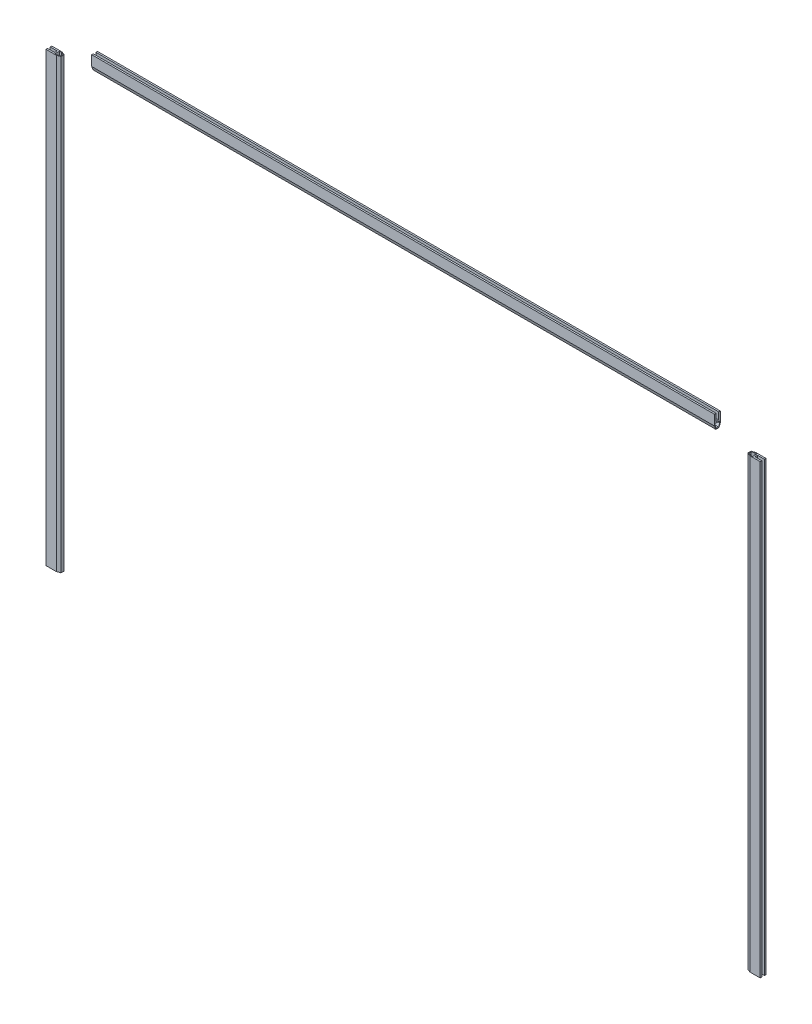
from build123d import *

# Parameters (mm, degrees)
JOINT_99168010_JOINT_DE_CARROSSERIE_1_DEPTH   = 700
JOINT_99168010_JOINT_DE_CARROSSERIE_1_2_DEPTH = 975
JOINT_99168010_JOINT_DE_CARROSSERIE_1_3_DEPTH = 700


with BuildPart() as part:
    # Sketch1 → Joint 99168010 JOINT DE CARROSSERIE(1) (new body)
    with BuildSketch(Plane(origin=(-548, 0, 0), x_dir=(-1, 0, 0), z_dir=(0, 1, 0))):
        Polygon((11, 4.5), (-5.005045161, 4.5), (-10.5, 2.5), (-10.5, -2.5), (-5.005045161, -4.5), (11, -4.5), (11, -2), (0, -2), (0, 2), (11, 2), align=None)
        Polygon((-4.82871818, 3.5), (-9.5, 1.799792462), (-9.5, -1.799792462), (-4.82871818, -3.5), (-2, -3.5), (-2, 3.5), align=None, mode=Mode.SUBTRACT)
    extrude(amount=JOINT_99168010_JOINT_DE_CARROSSERIE_1_DEPTH)


with BuildPart() as body_2:
    # Sketch1 on segment 2 (carried to segment 2) → Joint 99168010 JOINT DE CARROSSERIE_1 2 (new body)
    with BuildSketch(Plane(origin=(-487.5, 717.5, 0), x_dir=(0, 1, 0), z_dir=(1, 0, 0))):
        Polygon((11, 4.5), (-5.005045161, 4.5), (-10.5, 2.5), (-10.5, -2.5), (-5.005045161, -4.5), (11, -4.5), (11, -2), (0, -2), (0, 2), (11, 2), align=None)
        Polygon((-4.82871818, 3.5), (-9.5, 1.799792462), (-9.5, -1.799792462), (-4.82871818, -3.5), (-2, -3.5), (-2, 3.5), align=None, mode=Mode.SUBTRACT)
    extrude(amount=JOINT_99168010_JOINT_DE_CARROSSERIE_1_2_DEPTH)


with BuildPart() as body_3:
    # Sketch1 on segment 3 (carried to segment 3) → Joint 99168010 JOINT DE CARROSSERIE_1 3 (new body)
    with BuildSketch(Plane(origin=(548, 0, 0), x_dir=(1, 0, 0), z_dir=(0, 1, 0))):
        Polygon((11, 4.5), (-5.005045161, 4.5), (-10.5, 2.5), (-10.5, -2.5), (-5.005045161, -4.5), (11, -4.5), (11, -2), (0, -2), (0, 2), (11, 2), align=None)
        Polygon((-4.82871818, 3.5), (-9.5, 1.799792462), (-9.5, -1.799792462), (-4.82871818, -3.5), (-2, -3.5), (-2, 3.5), align=None, mode=Mode.SUBTRACT)
    extrude(amount=JOINT_99168010_JOINT_DE_CARROSSERIE_1_3_DEPTH)


solid = Compound([part.part, body_2.part, body_3.part])
